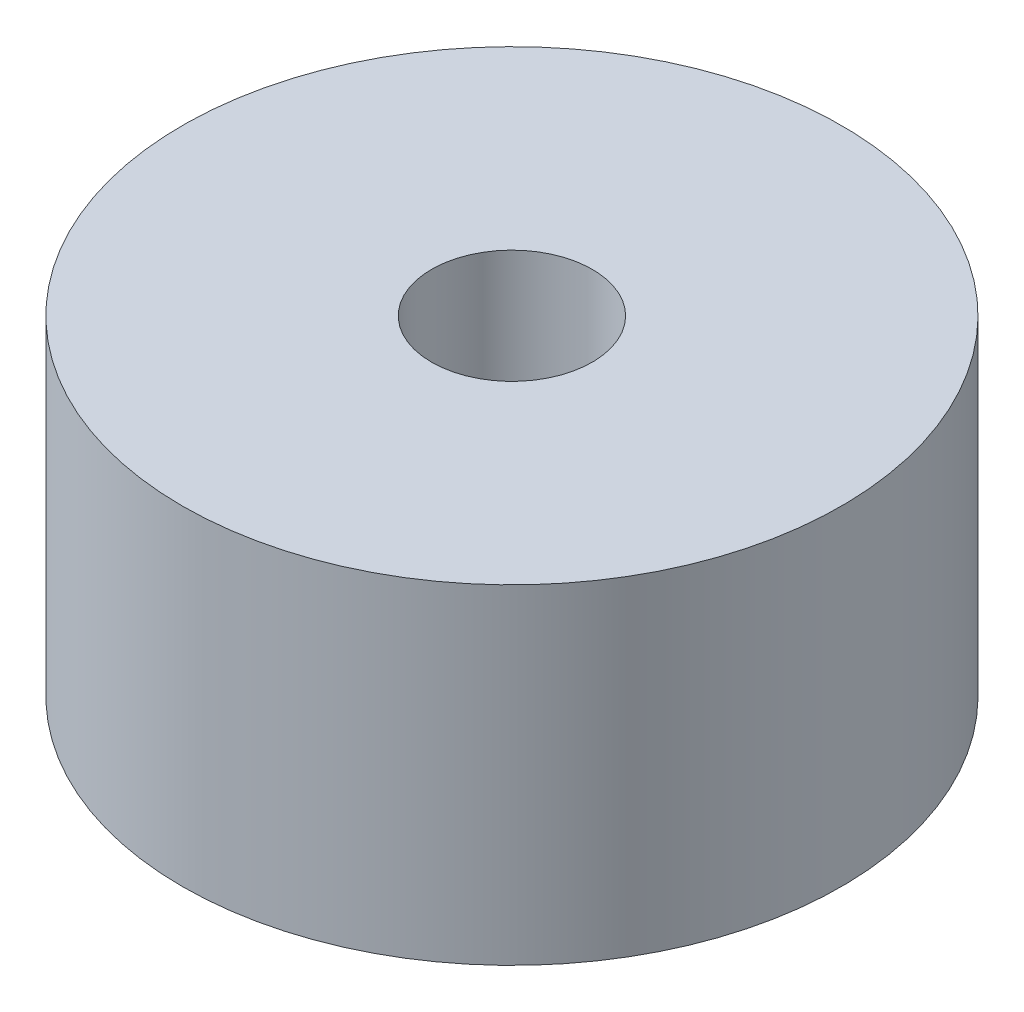
from build123d import *

# Parameters (mm, degrees)
SKETCH1_R           = 6.35
SKETCH1_R_2         = 1.5494
BOSS_EXTRUDE1_DEPTH = 6.35


with BuildPart() as part:
    # Sketch1 → Boss-Extrude1 (new body)
    with BuildSketch(Plane(origin=(0, 0, 0), x_dir=(1, 0, 0), z_dir=(0, 1, 0))):
        Circle(SKETCH1_R)
        Circle(SKETCH1_R_2, mode=Mode.SUBTRACT)
    extrude(amount=BOSS_EXTRUDE1_DEPTH)


solid = part.part
